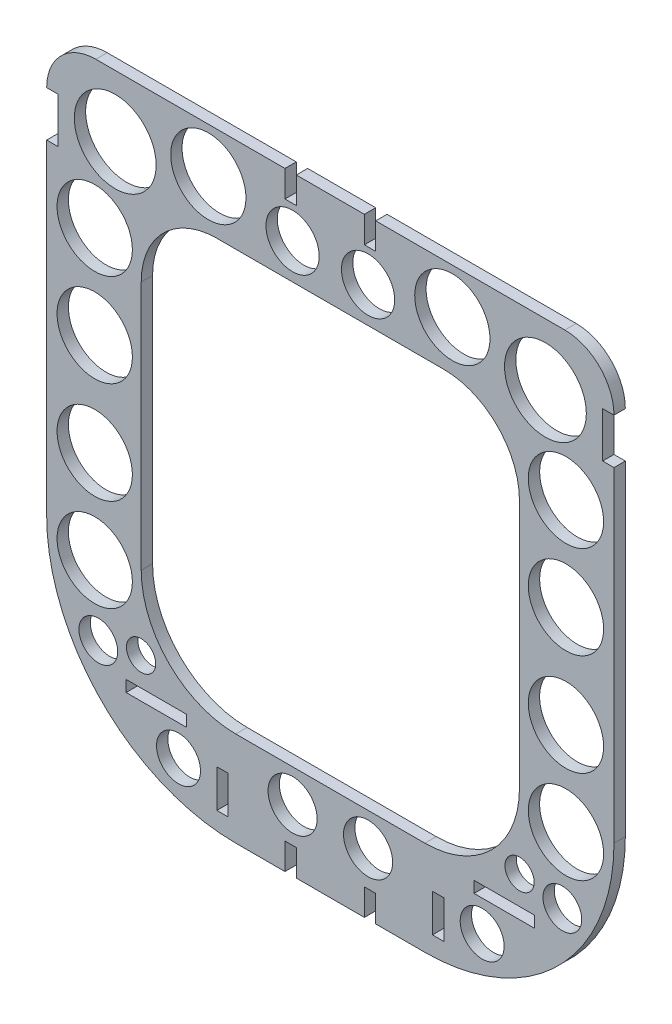
from build123d import *

# Parameters (mm, degrees)
BOSS_EXTRUDE1_DEPTH = 3
FILLET1_R           = 20
SKETCH2_W           = 3
SKETCH2_H           = 7
SKETCH2_W_2         = 16
SKETCH2_H_2         = 3
SKETCH2_H_3         = 10
SKETCH2_H_4         = 12
CUT_EXTRUDE1_DEPTH  = 10
SKETCH3_R           = 10.816374358
SKETCH3_R_2         = 9.958860775
SKETCH3_R_3         = 9.948633444
SKETCH3_R_4         = 7.040136574
SKETCH3_R_5         = 5.125609119
SKETCH3_R_6         = 6.486312195
SKETCH3_R_7         = 5.814914906
SKETCH3_R_8         = 3.86625454
CUT_EXTRUDE2_DEPTH  = 10


with BuildPart() as part:
    # Sketch1 → Boss-Extrude1 (new body)
    with BuildSketch(Plane.XY):
        with BuildLine():
            Line((-0.5, -84.19), (0.5, -84.19))
            Line((0.5, -84.19), (25, -84.19))
            ThreePointArc((25, -84.19), (60.355339059, -69.545339059), (75, -34.19))
            Line((75, -34.19), (75, 63.81))
            ThreePointArc((75, 63.81), (71.192388155, 73.002388155), (62, 76.81))
            Line((62, 76.81), (-62, 76.81))
            ThreePointArc((-62, 76.81), (-71.192388155, 73.002388155), (-75, 63.81))
            Line((-75, 63.81), (-75, -34.19))
            ThreePointArc((-75, -34.19), (-60.355339059, -69.545339059), (-25, -84.19))
            Line((-25, -84.19), (-0.5, -84.19))
        make_face()
        with BuildLine():
            Line((50, 51.81), (-50, 51.81))
            Line((-50, 51.81), (-50, -34.19))
            ThreePointArc((-50, -34.19), (-42.67766953, -51.86766953), (-25, -59.19))
            Line((-25, -59.19), (-0.5, -59.19))
            Line((-0.5, -59.19), (0.5, -59.19))
            Line((0.5, -59.19), (25, -59.19))
            ThreePointArc((25, -59.19), (42.67766953, -51.86766953), (50, -34.19))
            Line((50, -34.19), (50, 51.81))
        make_face(mode=Mode.SUBTRACT)
    extrude(amount=BOSS_EXTRUDE1_DEPTH)

    # Fillet1
    fillet1_edges = [part.edges().sort_by_distance(p)[0] for p in [
        (50, 51.81, 1.5),
        (-50, 51.81, 1.5),
    ]]
    fillet(fillet1_edges, radius=FILLET1_R)

    # Sketch2 → Cut-Extrude1 (cut)
    with BuildSketch(Plane(origin=(0, 0, 0), x_dir=(-1, 0, 0), z_dir=(0, 0, -1))):
        with Locations((-10.5, 73.31)):
            Rectangle(SKETCH2_W, SKETCH2_H)
        with Locations((-10.5, -80.69)):
            Rectangle(SKETCH2_W, SKETCH2_H)
        with Locations((10.5, -80.69)):
            Rectangle(SKETCH2_W, SKETCH2_H)
        with Locations((10.5, 73.31)):
            Rectangle(SKETCH2_W, SKETCH2_H)
        with Locations((46, -62.69)):
            Rectangle(SKETCH2_W_2, SKETCH2_H_2)
        with Locations((-46, -62.69)):
            Rectangle(SKETCH2_W_2, SKETCH2_H_2)
        with Locations((28.5, -74.19)):
            Rectangle(SKETCH2_W, SKETCH2_H_3)
        with Locations((-28.5, -74.19)):
            Rectangle(SKETCH2_W, SKETCH2_H_3)
        with Locations((-73.5, 57.81)):
            Rectangle(SKETCH2_W, SKETCH2_H_4)
        with Locations((73.5, 57.81)):
            Rectangle(SKETCH2_W, SKETCH2_H_4)
    extrude(amount=-CUT_EXTRUDE1_DEPTH, mode=Mode.SUBTRACT)

    # Sketch3 → Cut-Extrude2 (cut)
    with BuildSketch(Plane(origin=(0, 0, 0), x_dir=(-1, 0, 0), z_dir=(0, 0, -1))):
        with Locations((-56.872719069, 60.521134432)):
            Circle(SKETCH3_R)
        with Locations((-62.296765207, 38.027296035)):
            Circle(SKETCH3_R_2)
        with Locations((-62.296765207, 13.459557643)):
            Circle(SKETCH3_R_2)
        with Locations(Location((-62.296765207, -38.027296035, 0), (0, 0, 180))):
            Circle(SKETCH3_R_2)
        with Locations(Location((-62.296765207, -13.459557643, 0), (0, 0, 180))):
            Circle(SKETCH3_R_2)
        with Locations((-32.2590485, 64.887956773)):
            Circle(SKETCH3_R_3)
        with Locations((-9.981507512, 61.202530051)):
            Circle(SKETCH3_R_4)
        with Locations((-61.336948944, -55.95327759)):
            Circle(SKETCH3_R_5)
        with Locations((-9.981507512, -67.886000723)):
            Circle(SKETCH3_R_6)
        with Locations((-40.143007857, -72.338509355)):
            Circle(SKETCH3_R_7)
        with Locations((-50.027577019, -53.727023274)):
            Circle(SKETCH3_R_8)
        with Locations(Location((50.027577019, -53.727023274, 0), (0, 0, 180))):
            Circle(SKETCH3_R_8)
        with Locations(Location((40.143007857, -72.338509355, 0), (0, 0, 180))):
            Circle(SKETCH3_R_7)
        with Locations(Location((9.981507512, -67.886000723, 0), (0, 0, 180))):
            Circle(SKETCH3_R_6)
        with Locations(Location((61.336948944, -55.95327759, 0), (0, 0, 180))):
            Circle(SKETCH3_R_5)
        with Locations(Location((9.981507512, 61.202530051, 0), (0, 0, 180))):
            Circle(SKETCH3_R_4)
        with Locations(Location((32.2590485, 64.887956773, 0), (0, 0, 180))):
            Circle(SKETCH3_R_3)
        with Locations((62.296765207, -13.459557643)):
            Circle(SKETCH3_R_2)
        with Locations((62.296765207, -38.027296035)):
            Circle(SKETCH3_R_2)
        with Locations(Location((62.296765207, 13.459557643, 0), (0, 0, 180))):
            Circle(SKETCH3_R_2)
        with Locations(Location((62.296765207, 38.027296035, 0), (0, 0, 180))):
            Circle(SKETCH3_R_2)
        with Locations(Location((56.872719069, 60.521134432, 0), (0, 0, 180))):
            Circle(SKETCH3_R)
    extrude(amount=-CUT_EXTRUDE2_DEPTH, mode=Mode.SUBTRACT)


solid = part.part
